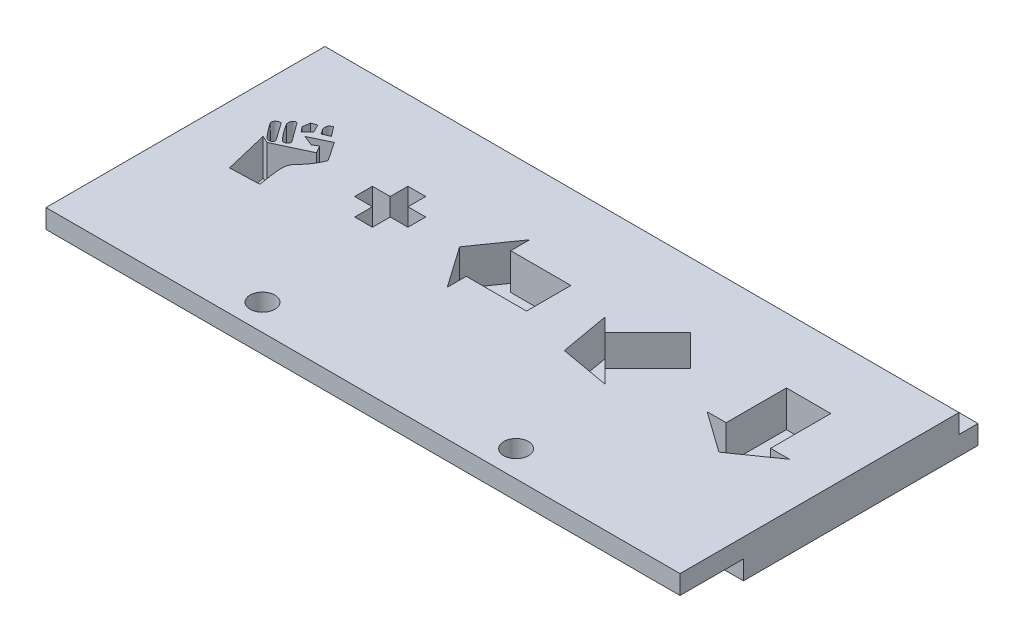
from build123d import *

# Parameters (mm, degrees)
SKETCH1_W           = 100
SKETCH1_H           = 50
BOSS_EXTRUDE1_DEPTH = 6
SKETCH2_W           = 10
SKETCH2_H           = 3
CUT_EXTRUDE1_DEPTH  = 101
SKETCH3_W           = 6
SKETCH3_H           = 34
BOSS_EXTRUDE2_DEPTH = 100
SKETCH4_W           = 2
SKETCH4_H           = 3
CUT_EXTRUDE2_DEPTH  = 101
SKETCH5_W           = 7.857142857
SKETCH5_H           = 12.5
CUT_EXTRUDE3_DEPTH  = 5.5
CUT_EXTRUDE4_DEPTH  = 5.7
CUT_EXTRUDE5_DEPTH  = 101.0000001
SKETCH10_R          = 1.95
CUT_EXTRUDE6_DEPTH  = 7
SKETCH11_R          = 1.95
CUT_EXTRUDE7_DEPTH  = 7


with BuildPart() as part:
    # Sketch1 → Boss-Extrude1 (new body)
    with BuildSketch(Plane(origin=(0, 0, 0), x_dir=(1, 0, 0), z_dir=(0, 1, 0))):
        with Locations((50, 25)):
            Rectangle(SKETCH1_W, SKETCH1_H)
    extrude(amount=BOSS_EXTRUDE1_DEPTH)

    # Sketch2 → Cut-Extrude1 (cut, through all)
    with BuildSketch(Plane(origin=(100, 0, 0), x_dir=(0, 0, -1), z_dir=(1, 0, 0))):
        with Locations((5, 1.5)):
            Rectangle(SKETCH2_W, SKETCH2_H)
    extrude(amount=-CUT_EXTRUDE1_DEPTH, mode=Mode.SUBTRACT)

    # Sketch3 → Boss-Extrude2 (add)
    with BuildSketch(Plane(origin=(100, 0, 0), x_dir=(0, 0, -1), z_dir=(1, 0, 0))):
        with Locations((47, 17)):
            Rectangle(SKETCH3_W, SKETCH3_H)
    extrude(amount=-BOSS_EXTRUDE2_DEPTH)

    # Sketch4 → Cut-Extrude2 (cut, through all)
    with BuildSketch(Plane.ZY):
        with Locations((-45, 32.5)):
            Rectangle(SKETCH4_W, SKETCH4_H)
    extrude(amount=-CUT_EXTRUDE2_DEPTH, mode=Mode.SUBTRACT)

    # Sketch5 → Cut-Extrude3 (cut)
    with BuildSketch(Plane(origin=(0, 0, -44), x_dir=(-1, 0, 0), z_dir=(0, 0, -1))):
        with BuildLine():
            Line((-45.088169643, 17.571428571), (-45.439732143, 17.454241071))
            Line((-45.439732143, 17.454241071), (-48.056919643, 14.901227679))
            Line((-48.056919643, 14.901227679), (-48.098772321, 14.76171875))
            Line((-48.098772321, 14.76171875), (-48.107142857, 12.309151786))
            Line((-48.107142857, 12.309151786), (-48.059709821, 12.0859375))
            Line((-48.059709821, 12.0859375), (-45.609933036, 9.619419643))
            ThreePointArc((-45.609933036, 9.619419643), (-45.303061085, 9.424580045), (-44.945870536, 9.357142857))
            Line((-44.945870536, 9.357142857), (-38.319196429, 9.376674107))
            ThreePointArc((-38.319196429, 9.376674107), (-37.810119286, 9.488456034), (-37.392857143, 9.80078125))
            Line((-37.392857143, 9.80078125), (-37.392857143, 23.740513393))
            ThreePointArc((-37.392857143, 23.740513393), (-38.102358714, 23.844903984), (-38.818638393, 23.880022321))
            Line((-38.818638393, 23.880022321), (-38.821428571, 17.571428571))
            Line((-38.821428571, 17.571428571), (-40.116071429, 17.571428571))
            Line((-40.116071429, 17.571428571), (-46.991071429, 24.259486607))
            ThreePointArc((-46.991071429, 24.259486607), (-47.787451466, 24.334800239), (-48.031808036, 23.573102679))
            Line((-48.031808036, 23.573102679), (-41.681361607, 17.571428571))
            Line((-41.681361607, 17.571428571), (-45.088169643, 17.571428571))
        make_face()
        Polygon((-46.678571429, 12.557477679), (-44.725446429, 10.607142857), (-38.821428571, 10.607142857), (-38.821428571, 16.321428571), (-44.708705357, 16.321428571), (-46.678571429, 14.354352679), align=None, mode=Mode.SUBTRACT)
        with BuildLine():
            Line((-17.038504464, 9.619419643), (-19.48828125, 12.0859375))
            Line((-19.48828125, 12.0859375), (-19.535714286, 12.309151786))
            Line((-19.535714286, 12.309151786), (-19.52734375, 14.758928571))
            Line((-19.52734375, 14.758928571), (-19.485491071, 14.904017857))
            Line((-19.485491071, 14.904017857), (-16.896205357, 17.454241071))
            Line((-16.896205357, 17.454241071), (-16.555803571, 17.571428571))
            Line((-16.555803571, 17.571428571), (-10.25, 17.571428571))
            Line((-10.25, 17.571428571), (-10.244419643, 23.868861607))
            ThreePointArc((-10.244419643, 23.868861607), (-9.462763686, 24.582553037), (-8.821428571, 23.740513393))
            Line((-8.821428571, 23.740513393), (-8.821428571, 9.80078125))
            ThreePointArc((-8.821428571, 9.80078125), (-9.238690714, 9.488456034), (-9.747767857, 9.376674107))
            Line((-9.747767857, 9.376674107), (-16.374441964, 9.357142857))
            ThreePointArc((-16.374441964, 9.357142857), (-16.731632514, 9.424580045), (-17.038504464, 9.619419643))
        make_face()
        Polygon((-18.107142857, 12.563058036), (-16.154017857, 10.607142857), (-10.25, 10.607142857), (-10.25, 16.321428571), (-16.137276786, 16.321428571), (-18.107142857, 14.368303571), align=None, mode=Mode.SUBTRACT)
        with BuildLine():
            Line((-33.821428571, 10.1328125), (-33.815848214, 23.880022321))
            ThreePointArc((-33.815848214, 23.880022321), (-33.601713039, 24.293327013), (-33.140625, 24.357142857))
            Line((-33.140625, 24.357142857), (-23.508928571, 24.357142857))
            ThreePointArc((-23.508928571, 24.357142857), (-23.212822653, 23.985866281), (-23.107142857, 23.522879464))
            Line((-23.107142857, 23.522879464), (-23.107142857, 9.78125))
            ThreePointArc((-23.107142857, 9.78125), (-23.280423047, 9.477022359), (-23.609375, 9.357142857))
            Line((-23.609375, 9.357142857), (-33.235491071, 9.379464286))
            ThreePointArc((-33.235491071, 9.379464286), (-33.657785084, 9.655552078), (-33.821428571, 10.1328125))
        make_face()
        with Locations((-28.464285715, 16.857142857)):
            Rectangle(SKETCH5_W, SKETCH5_H, mode=Mode.SUBTRACT)
        with BuildLine():
            Line((-62.392857143, 10.1328125), (-62.387276786, 23.880022321))
            ThreePointArc((-62.387276786, 23.880022321), (-62.17314161, 24.293327013), (-61.712053571, 24.357142857))
            Line((-61.712053571, 24.357142857), (-52.080357143, 24.357142857))
            ThreePointArc((-52.080357143, 24.357142857), (-51.784251224, 23.985866281), (-51.678571429, 23.522879464))
            Line((-51.678571429, 23.522879464), (-51.678571429, 9.78125))
            ThreePointArc((-51.678571429, 9.78125), (-51.851851619, 9.477022359), (-52.180803571, 9.357142857))
            Line((-52.180803571, 9.357142857), (-61.806919643, 9.379464286))
            ThreePointArc((-61.806919643, 9.379464286), (-62.283572717, 9.613272807), (-62.392857143, 10.1328125))
        make_face()
        with Locations((-57.035714286, 16.857142857)):
            Rectangle(SKETCH5_W, SKETCH5_H, mode=Mode.SUBTRACT)
        with BuildLine():
            Line((-76.516741071, 10.224888393), (-69.834263393, 16.890625))
            Line((-69.834263393, 16.890625), (-76.508370536, 23.564732143))
            ThreePointArc((-76.508370536, 23.564732143), (-76.263865977, 24.33823157), (-75.456473214, 24.259486607))
            Line((-75.456473214, 24.259486607), (-68.670758929, 17.571428571))
            Line((-68.670758929, 17.571428571), (-67.392857143, 17.571428571))
            Line((-67.392857143, 17.571428571), (-67.390066964, 23.880022321))
            ThreePointArc((-67.390066964, 23.880022321), (-66.613914042, 24.456808533), (-65.964285714, 23.740513393))
            Line((-65.964285714, 23.740513393), (-65.964285714, 9.789620536))
            ThreePointArc((-65.964285714, 9.789620536), (-66.815504738, 9.403127861), (-67.392857143, 10.138392857))
            Line((-67.392857143, 10.138392857), (-67.392857143, 16.321428571))
            Line((-67.392857143, 16.321428571), (-68.66796875, 16.321428571))
            Line((-68.66796875, 16.321428571), (-75.489955357, 9.465959821))
            ThreePointArc((-75.489955357, 9.465959821), (-76.031889018, 9.806810078), (-76.516741071, 10.224888393))
        make_face()
        with BuildLine():
            Line((-81.678571429, 10.130022321), (-81.678571429, 21.2265625))
            Line((-81.678571429, 21.2265625), (-83.5703125, 23.107142857))
            Line((-83.5703125, 23.107142857), (-87.585379464, 23.107142857))
            Line((-87.585379464, 23.107142857), (-89.535714286, 21.151227679))
            Line((-89.535714286, 21.151227679), (-89.535714286, 9.770089286))
            ThreePointArc((-89.535714286, 9.770089286), (-90.273009404, 9.862916097), (-90.964285714, 10.135602679))
            Line((-90.964285714, 10.135602679), (-90.883370536, 21.751116071))
            Line((-90.883370536, 21.751116071), (-88.2578125, 24.320870536))
            Line((-88.2578125, 24.320870536), (-87.872767857, 24.357142857))
            Line((-87.872767857, 24.357142857), (-82.970424107, 24.357142857))
            Line((-82.970424107, 24.357142857), (-82.7890625, 24.234375))
            Line((-82.7890625, 24.234375), (-80.303013393, 21.742745536))
            Line((-80.303013393, 21.742745536), (-80.25, 21.48046875))
            Line((-80.25, 21.48046875), (-80.25, 9.78125))
            ThreePointArc((-80.25, 9.78125), (-80.985264996, 9.869705022), (-81.678571429, 10.130022321))
        make_face()
    extrude(amount=CUT_EXTRUDE3_DEPTH, mode=Mode.SUBTRACT)

    # Sketch8 → Cut-Extrude4 (cut)
    with BuildSketch(Plane(origin=(0, 6, 0), x_dir=(1, 0, 0), z_dir=(0, 1, 0))):
        with BuildLine():
            Line((7.011617647, 30.077205882), (8.955082743, 27.33260299))
            add(Edge.make_bspline(
                [(8.955082743, 27.33260299), (9.12959235, 26.730722395), (8.207708735, 26.573406529), (7.899470003, 26.933823529)],
                knots=[0, 0, 0, 0, 1, 1, 1, 1], degree=3))
            add(Edge.make_bspline(
                [(7.899470003, 26.933823529), (6.967481131, 27.995956124), (6.173874947, 29.162344961)],
                knots=[0, 0, 0, 1, 1, 1], degree=2))
            add(Edge.make_bspline(
                [(6.173874947, 29.162344961), (5.827065663, 29.66494419), (6.530628947, 30.242627585), (7.011617647, 30.077205882)],
                knots=[0, 0, 0, 0, 1, 1, 1, 1], degree=3))
        make_face()
        with BuildLine():
            Line((8.476184036, 31.013434386), (10.320441176, 28.506054806))
            add(Edge.make_bspline(
                [(10.320441176, 28.506054806), (10.75287522, 28.022402696), (9.844480118, 27.32594185), (9.464423283, 27.806698869)],
                knots=[0, 0, 0, 0, 1, 1, 1, 1], degree=3))
            add(Edge.make_bspline(
                [(7.548449232, 30.408088235), (8.369245022, 29.00368602), (9.464423283, 27.806698869)],
                knots=[0, 0, 0, 1, 1, 1], degree=2))
            add(Edge.make_bspline(
                [(7.548449232, 30.408088235), (7.420862108, 30.780822958), (7.657281624, 31.572935659), (8.169705882, 31.400735294)],
                knots=[0, 0, 0, 0, 1, 1, 1, 1], degree=3))
            add(Edge.make_bspline(
                [(8.169705882, 31.400735294), (8.365163665, 31.240936083), (8.476184036, 31.013434386)],
                knots=[0, 0, 0, 1, 1, 1], degree=2))
        make_face()
        Polygon((10.816764706, 31.400735294), (10.155, 32.724264706), (9.327794118, 32.393382353), (9.162352941, 31.235294118), (9.824117647, 30.408088235), align=None)
        with BuildLine():
            Line((12.802058824, 32.227941176), (11.643970588, 33.716911765))
            add(Edge.make_bspline(
                [(11.643970588, 33.716911765), (10.801410064, 33.411012177), (11.092331374, 32.550744981)],
                knots=[0, 0, 0, 1, 1, 1], degree=2))
            Line((11.092331374, 32.550744981), (11.643970588, 31.731617647))
            Line((11.643970588, 31.731617647), (12.802058824, 32.227941176))
        make_face()
        with BuildLine():
            Line((13.193009945, 29.973529412), (13.854774651, 28.815441176))
            Line((13.854774651, 28.815441176), (8.560657004, 26.333823529))
            Line((8.560657004, 26.333823529), (7.402568768, 26.830147059))
            Line((7.402568768, 26.830147059), (9.056980533, 19.881617647))
            Line((9.056980533, 19.881617647), (13.689333474, 20.047058824))
            add(Edge.make_bspline(
                [(13.689333474, 20.047058824), (12.450227116, 27.171920383), (13.777231511, 23.836713066), (15.840068768, 28.65)],
                knots=[0, 0, 0, 0, 1, 1, 1, 1], degree=3))
            Line((15.840068768, 28.65), (13.854774651, 31.627941176))
            Line((13.854774651, 31.627941176), (10.711392298, 30.138970588))
            Line((10.711392298, 30.138970588), (12.365804063, 29.477205882))
            Line((12.365804063, 29.477205882), (13.193009945, 29.973529412))
        make_face()
        Polygon((31.240068768, 25.85), (31.240068768, 28.65), (28.440068768, 28.65), (28.440068768, 31.45), (25.640068768, 31.45), (25.640068768, 28.65), (22.840068768, 28.65), (22.840068768, 25.85), (25.640068768, 25.85), (25.640068768, 23.05), (28.440068768, 23.05), (28.440068768, 25.85), align=None)
        Polygon((52.041417767, 30.75), (42.541417767, 30.75), (42.541417767, 33.75), (37.990068768, 27.25), (42.541417767, 20.75), (42.541417767, 23.75), (52.041417767, 23.75), align=None)
        Polygon((60.419322104, 21.339322104), (59.041417767, 29.153805922), (61.16273811, 27.032485579), (67.880252532, 33.75), (72.83, 28.800252532), (66.112485579, 22.08273811), (68.233805922, 19.961417767), align=None)
        Polygon((90.03, 33.75), (90.03, 24.25), (93.03, 24.25), (86.476783646, 19.661388509), (80.03, 24.25), (83.03, 24.25), (83.03, 33.75), align=None)
    extrude(amount=-CUT_EXTRUDE4_DEPTH, mode=Mode.SUBTRACT)

    # Sketch9 → Cut-Extrude5 (cut, through all)
    with BuildSketch(Plane.ZY):
        Polygon((-50, 6), (-50, 0), (-47, 0), (-47, 3), (-44, 3), (-44, 6), (-44, 34), (-50, 34), align=None)
    extrude(amount=-CUT_EXTRUDE5_DEPTH, mode=Mode.SUBTRACT)

    # Sketch10 → Cut-Extrude6 (cut, through all)
    with BuildSketch(Plane(origin=(0, 6, 0), x_dir=(1, 0, 0), z_dir=(0, 1, 0))):
        with Locations((70, 4.144406286)):
            Circle(SKETCH10_R)
    extrude(amount=-CUT_EXTRUDE6_DEPTH, mode=Mode.SUBTRACT)

    # Sketch11 → Cut-Extrude7 (cut, through all)
    with BuildSketch(Plane(origin=(0, 6, 0), x_dir=(1, 0, 0), z_dir=(0, 1, 0))):
        with Locations((30, 4.144406286)):
            Circle(SKETCH11_R)
    extrude(amount=-CUT_EXTRUDE7_DEPTH, mode=Mode.SUBTRACT)


solid = part.part
